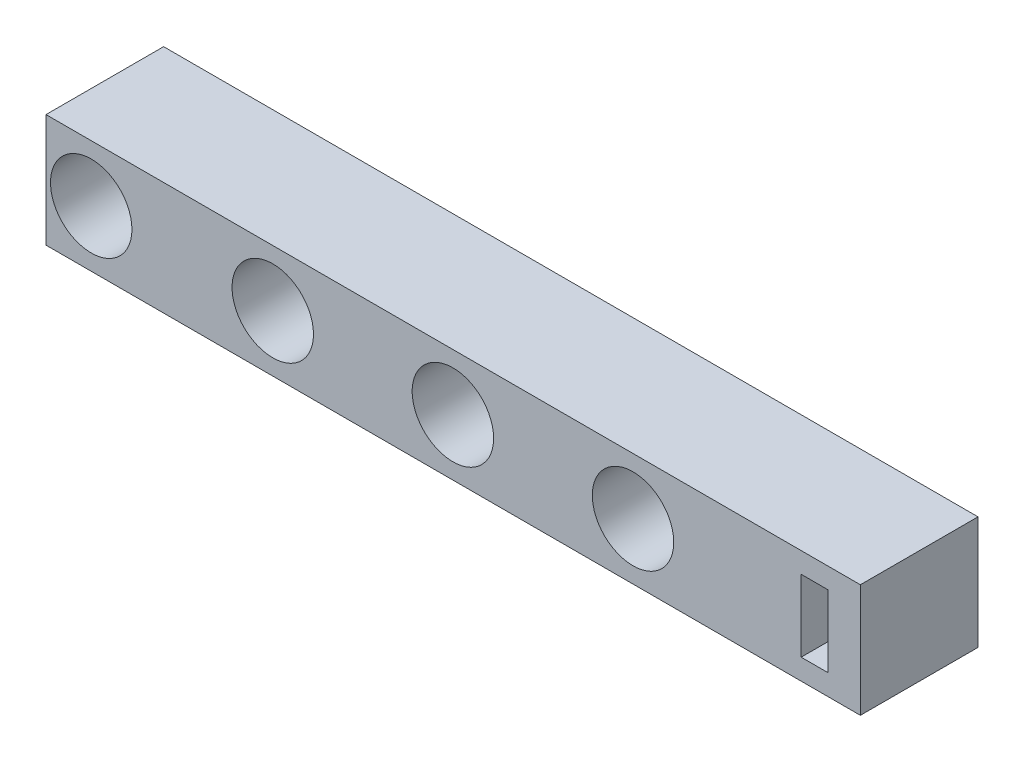
from build123d import *

# Parameters (mm, degrees)
SKIZZE1_W                        = 180
SKIZZE1_H                        = 25
AUFSATZ_LINEAR_AUSTRAGEN1_DEPTH  = 26
F_18_0_18_DURCHMESSER_BOHRUNG2_D = 18
SKIZZE9_W                        = 5.897581214
SKIZZE9_H                        = 15.867301838
SCHNITT_LINEAR_AUSTRAGEN1_DEPTH  = 27


with BuildPart() as part:
    # Skizze1 → Aufsatz-Linear austragen1 (new body)
    with BuildSketch(Plane.XY):
        with Locations((90, 12.5)):
            Rectangle(SKIZZE1_W, SKIZZE1_H)
    extrude(amount=AUFSATZ_LINEAR_AUSTRAGEN1_DEPTH)

    # Ø18.0 (18) Durchmesser Bohrung2 (through all)
    with Locations(Plane.XY.offset(26)):
        with Locations((9.995618269, 12.5), (50.121303026, 12.5), (89.934725645, 12.5), (129.748148264, 12.5)):
            Hole(F_18_0_18_DURCHMESSER_BOHRUNG2_D / 2)

    # Skizze9 → Schnitt-Linear austragen1 (cut, through all)
    with BuildSketch(Plane.XY.offset(26)):
        with Locations((169.861933283, 12.524643843)):
            Rectangle(SKIZZE9_W, SKIZZE9_H)
    extrude(amount=-SCHNITT_LINEAR_AUSTRAGEN1_DEPTH, mode=Mode.SUBTRACT)


solid = part.part
